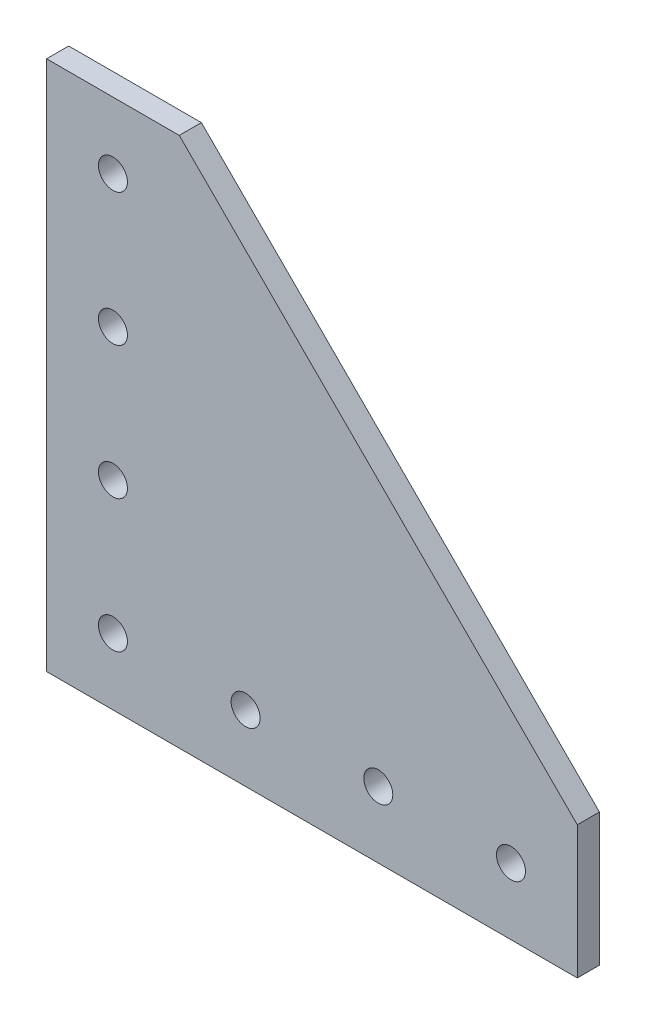
from build123d import *

# Parameters (mm, degrees)
BOSS_EXTRUDE1_DEPTH      = 3.175
BOSS_EXTRUDE1_DEPTH_BACK = 3.175
SKETCH4_R                = 4.1656
CUT_EXTRUDE1_DEPTH       = 7.35


with BuildPart() as part:
    # Sketch3 → Boss-Extrude1 (new body, two sides)
    with BuildSketch(Plane.XY) as boss_extrude1_sk:
        Polygon((76.2, -38.1), (76.2, -76.2), (-76.2, -76.2), (-76.2, 76.2), (-38.1, 76.2), align=None)
    extrude(amount=BOSS_EXTRUDE1_DEPTH)
    extrude(boss_extrude1_sk.sketch, amount=-BOSS_EXTRUDE1_DEPTH_BACK)

    # Sketch4 → Cut-Extrude1 (cut, through all)
    with BuildSketch(Plane.XY.offset(3.175)):
        with Locations((-57.15, -57.15)):
            Circle(SKETCH4_R)
        with Locations((-19.05, -57.15)):
            Circle(SKETCH4_R)
        with Locations((19.05, -57.15)):
            Circle(SKETCH4_R)
        with Locations((-57.15, -19.05)):
            Circle(SKETCH4_R)
        with Locations((-57.15, 19.05)):
            Circle(SKETCH4_R)
        with Locations((57.15, -57.15)):
            Circle(SKETCH4_R)
        with Locations((-57.15, 57.15)):
            Circle(SKETCH4_R)
    extrude(amount=-CUT_EXTRUDE1_DEPTH, mode=Mode.SUBTRACT)


solid = part.part
